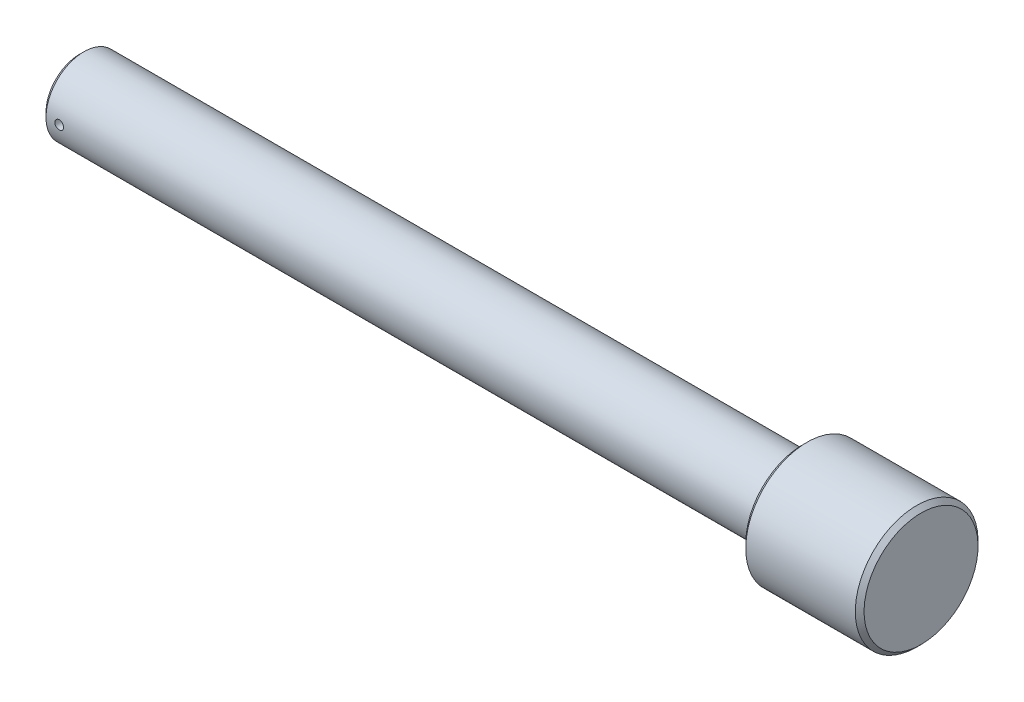
from build123d import *

# Parameters (mm, degrees)
ESQUISSE2_R                  = 1
ENL_V_MAT_EXTRU_1_DEPTH      = 15
ENL_V_MAT_EXTRU_1_DEPTH_BACK = 15


with BuildPart() as part:
    # Esquisse1 → Révolution1 (revolve)
    with BuildSketch(Plane.XY, mode=Mode.PRIVATE) as r_volution1_sk:
        Polygon((0, 0), (0, 7.65), (1, 8.65), (165, 8.65), (165, 13), (166, 14), (191, 14), (192, 13), (192, 0), align=None)
    revolve(r_volution1_sk.sketch.rotate(Axis((0, 0, 0), (1, 0, 0)), 180), axis=Axis((0, 0, 0), (1, 0, 0)))  # turned: the seam where the file's is

    # Esquisse2 → Enlèv. mat.-Extru.1 (cut, two sides)
    with BuildSketch(Plane.XY) as enl_v_mat_extru_1_sk:
        with Locations((4, 0)):
            Circle(ESQUISSE2_R)
    extrude(amount=ENL_V_MAT_EXTRU_1_DEPTH, mode=Mode.SUBTRACT)
    extrude(enl_v_mat_extru_1_sk.sketch, amount=-ENL_V_MAT_EXTRU_1_DEPTH_BACK, mode=Mode.SUBTRACT)


solid = part.part
